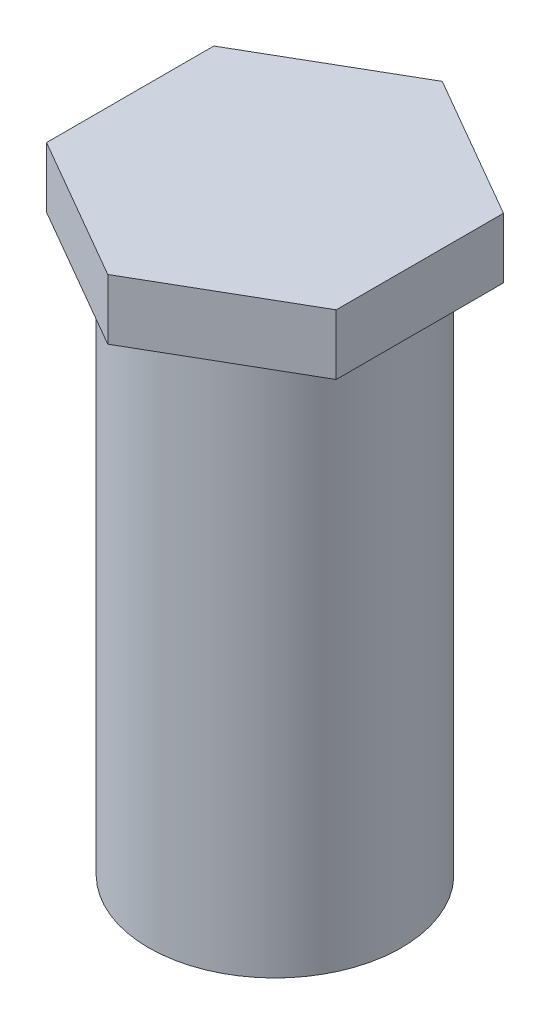
from build123d import *

# Parameters (mm, degrees)
CROQUIS1_W                = 2.095
CROQUIS1_H                = 10
SALIENTE_EXTRUIR1_DEPTH   = 1
TALADRO_ROSCADO_M31_D     = 2.5
TALADRO_ROSCADO_M31_DEPTH = 4
TALADRO_ROSCADO_M31_TIP   = 0.751075774


with BuildPart() as part:
    # Croquis1 → Revolución1 (revolve)
    with BuildSketch(Plane.XY):
        with Locations((1.0475, -5)):
            Rectangle(CROQUIS1_W, CROQUIS1_H)
    revolve(axis=Axis((0, 0, 0), (0, -1, 0)))

    # Croquis2 → Saliente-Extruir1 (add)
    with BuildSketch(Plane(origin=(0, 0, 0), x_dir=(1, 0, 0), z_dir=(0, 1, 0))):
        Polygon((2.4, -1.385640646), (2.4, 1.385640646), (0, 2.771281292), (-2.4, 1.385640646), (-2.4, -1.385640646), (0, -2.771281292), align=None)
    extrude(amount=-SALIENTE_EXTRUIR1_DEPTH)

    # Taladro roscado M31
    with Locations(Plane(origin=(0, -10, 0), x_dir=(-1, 0, 0), z_dir=(0, -1, 0))):
        with Locations((0, 0)):
            Hole(TALADRO_ROSCADO_M31_D / 2, depth=TALADRO_ROSCADO_M31_DEPTH)
            with Locations((0, 0, -(TALADRO_ROSCADO_M31_DEPTH + TALADRO_ROSCADO_M31_TIP / 2))):  # 118° drill point
                Cone(0, TALADRO_ROSCADO_M31_D / 2, TALADRO_ROSCADO_M31_TIP, mode=Mode.SUBTRACT)


solid = part.part
